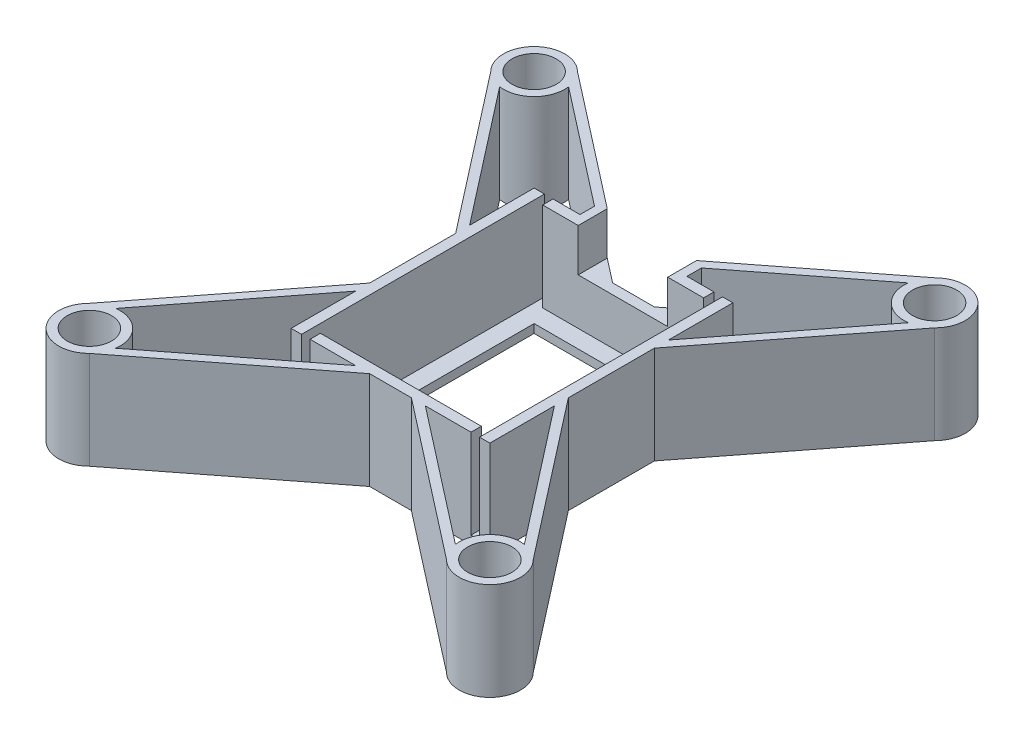
from build123d import *

# Parameters (mm, degrees)
SKETCH1_R           = 3.1
BOSS_EXTRUDE4_DEPTH = 13.7
SKETCH6_W           = 24.96
SKETCH6_H           = 31.16
CUT_EXTRUDE1_DEPTH  = 12.5
SKETCH7_W           = 19.96
SKETCH7_H           = 26.16
CUT_EXTRUDE2_DEPTH  = 12.5
SKETCH9_W           = 1.2
SKETCH9_H           = 12.5
CUT_EXTRUDE3_DEPTH  = 1.45
SKETCH10_W          = 1.2
SKETCH10_H          = 12.5
CUT_EXTRUDE4_DEPTH  = 1.45
CUT_EXTRUDE5_DEPTH  = 1.5
SKETCH12_W          = 7.5
SKETCH12_H          = 6
CUT_EXTRUDE6_DEPTH  = 20.892135624
BOSS_EXTRUDE5_DEPTH = 6
BOSS_EXTRUDE6_DEPTH = 7.7


with BuildPart() as part:
    # Sketch1 → Boss-Extrude4 (new body)
    with BuildSketch(Plane(origin=(0, 0, 0), x_dir=(1, 0, 0), z_dir=(0, 1, 0))):
        with BuildLine():
            Line((-1.559985024, 16.088570711), (-23.661955043, 33.271658997))
            ThreePointArc((-23.661955043, 33.271658997), (-29.74307331, 33.27087194), (-29.742286254, 27.189753673))
            Line((-29.742286254, 27.189753673), (-12.559985024, 5.088570711))
            Line((-12.559985024, 5.088570711), (-12.559985024, -6.971429289))
            Line((-12.559985024, -6.971429289), (-29.742286254, -29.072612251))
            ThreePointArc((-29.742286254, -29.072612251), (-29.74307331, -35.153730518), (-23.661955043, -35.154517574))
            Line((-23.661955043, -35.154517574), (-1.559985024, -17.971429289))
            Line((-1.559985024, -17.971429289), (4.300014976, -17.971429289))
            Line((4.300014976, -17.971429289), (26.401984994, -35.154517574))
            ThreePointArc((26.401984994, -35.154517574), (32.483103261, -35.153730518), (32.482316205, -29.072612251))
            Line((32.482316205, -29.072612251), (15.300014976, -6.971429289))
            Line((15.300014976, -6.971429289), (15.300014976, 5.088570711))
            Line((15.300014976, 5.088570711), (32.482316205, 27.189753673))
            ThreePointArc((32.482316205, 27.189753673), (32.483103261, 33.27087194), (26.401984994, 33.271658997))
            Line((26.401984994, 33.271658997), (4.300014976, 16.088570711))
            Line((4.300014976, 16.088570711), (-1.559985024, 16.088570711))
        make_face()
        with BuildLine():
            Line((15.300014976, -17.971429289), (15.300014976, -8.926547914))
            Line((15.300014976, -8.926547914), (30.013101167, -27.851638652))
            ThreePointArc((30.013101167, -27.851638652), (26.40152787, -29.073069325), (25.180248217, -32.684693693))
            Line((25.180248217, -32.684693693), (6.255121178, -17.971429289))
            Line((6.255121178, -17.971429289), (15.300014976, -17.971429289))
        make_face(mode=Mode.SUBTRACT)
        with Locations((-26.702120648, -32.113564912)):
            Circle(SKETCH1_R, mode=Mode.SUBTRACT)
        with BuildLine():
            Line((-12.559985024, -8.926547914), (-12.559985024, -17.971429289))
            Line((-12.559985024, -17.971429289), (-3.515091227, -17.971429289))
            Line((-3.515091227, -17.971429289), (-22.440218266, -32.684693693))
            ThreePointArc((-22.440218266, -32.684693693), (-23.661497919, -29.073069325), (-27.273071216, -27.851638652))
            Line((-27.273071216, -27.851638652), (-12.559985024, -8.926547914))
        make_face(mode=Mode.SUBTRACT)
        with BuildLine():
            Line((-3.515091227, 16.088570711), (-12.559985024, 16.088570711))
            Line((-12.559985024, 16.088570711), (-12.559985024, 7.043689336))
            Line((-12.559985024, 7.043689336), (-27.273071216, 25.968780075))
            ThreePointArc((-27.273071216, 25.968780075), (-23.661497919, 27.190210747), (-22.440218266, 30.801835115))
            Line((-22.440218266, 30.801835115), (-3.515091227, 16.088570711))
        make_face(mode=Mode.SUBTRACT)
        with Locations((-26.702120648, 30.230706335)):
            Circle(SKETCH1_R, mode=Mode.SUBTRACT)
        with BuildLine():
            Line((15.300014976, 7.043689336), (15.300014976, 16.088570711))
            Line((15.300014976, 16.088570711), (6.255121178, 16.088570711))
            Line((6.255121178, 16.088570711), (25.180248217, 30.801835115))
            ThreePointArc((25.180248217, 30.801835115), (26.40152787, 27.190210747), (30.013101167, 25.968780075))
            Line((30.013101167, 25.968780075), (15.300014976, 7.043689336))
        make_face(mode=Mode.SUBTRACT)
        with Locations((29.442150599, 30.230706335)):
            Circle(SKETCH1_R, mode=Mode.SUBTRACT)
        with Locations((29.442150599, -32.113564912)):
            Circle(SKETCH1_R, mode=Mode.SUBTRACT)
    extrude(amount=BOSS_EXTRUDE4_DEPTH)

    # Sketch6 → Cut-Extrude1 (cut)
    with BuildSketch(Plane(origin=(0, 13.7, 0), x_dir=(1, 0, 0), z_dir=(0, 1, 0))):
        with Locations((1.370014976, -0.941429289)):
            Rectangle(SKETCH6_W, SKETCH6_H)
    extrude(amount=-CUT_EXTRUDE1_DEPTH, mode=Mode.SUBTRACT)

    # Sketch7 → Cut-Extrude2 (cut)
    with BuildSketch(Plane(origin=(0, 1.2, 0), x_dir=(1, 0, 0), z_dir=(0, 1, 0))):
        with Locations((1.370014976, -0.941429289)):
            Rectangle(SKETCH7_W, SKETCH7_H)
    extrude(amount=-CUT_EXTRUDE2_DEPTH, mode=Mode.SUBTRACT)

    # Sketch9 → Cut-Extrude3 (cut)
    with BuildSketch(Plane.XY.offset(-14.638570711)):
        with Locations((-10.509985024, 7.45)):
            Rectangle(SKETCH9_W, SKETCH9_H)
        with Locations((13.250014976, 7.45)):
            Rectangle(SKETCH9_W, SKETCH9_H)
    extrude(amount=-CUT_EXTRUDE3_DEPTH, mode=Mode.SUBTRACT)

    # Sketch10 → Cut-Extrude4 (cut)
    with BuildSketch(Plane(origin=(0, 0, 16.521429289), x_dir=(-1, 0, 0), z_dir=(0, 0, -1))):
        with Locations((-13.250014976, 7.45)):
            Rectangle(SKETCH10_W, SKETCH10_H)
        with Locations((10.509985024, 7.45)):
            Rectangle(SKETCH10_W, SKETCH10_H)
    extrude(amount=-CUT_EXTRUDE4_DEPTH, mode=Mode.SUBTRACT)

    # Sketch11 → Cut-Extrude5 (cut)
    with BuildSketch(Plane.XZ):
        Polygon((-26.881022326, -29.561079875), (-26.032494188, -30.409608013), (-22.146132163, -26.523245987), (-22.9946603, -25.67471785), align=None)
        Polygon((24.886162114, -26.523245987), (25.734690251, -25.67471785), (29.621052277, -29.561079875), (28.772524139, -30.409608013), align=None)
        Polygon((29.621052277, 31.443938453), (28.772524139, 32.29246659), (24.886162114, 28.406104565), (25.734690251, 27.557576427), align=None)
        Polygon((-22.146132163, 28.406104565), (-22.9946603, 27.557576427), (-26.881022326, 31.443938453), (-26.032494188, 32.29246659), align=None)
    extrude(amount=-CUT_EXTRUDE5_DEPTH, mode=Mode.SUBTRACT)

    # Sketch12 → Cut-Extrude6 (cut, through all)
    with BuildSketch(Plane.XY.offset(-14.638570711)):
        with Locations((-2.379985024, 10.7)):
            Rectangle(SKETCH12_W, SKETCH12_H)
        with Locations((5.120014976, 10.7)):
            Rectangle(SKETCH12_W, SKETCH12_H)
    extrude(amount=-CUT_EXTRUDE6_DEPTH, mode=Mode.SUBTRACT)

    # Sketch14 → Boss-Extrude5 (add)
    with BuildSketch(Plane(origin=(0, 7.7, 0), x_dir=(1, 0, 0), z_dir=(0, 1, 0))):
        Polygon((-6.129985024, 19.641498953), (-6.129985024, 14.638570711), (-4.929985024, 14.638570711), (-4.929985024, 18.708563747), align=None)
        Polygon((8.870014976, 19.641498953), (8.870014976, 14.638570711), (7.62204126, 14.638570711), (7.62204126, 18.671266773), align=None)
    extrude(amount=BOSS_EXTRUDE5_DEPTH)

    # Sketch15 → Boss-Extrude6 (add)
    with BuildSketch(Plane.XZ.offset(-7.7)):
        Polygon((-6.129985024, -16.088570711), (-6.129985024, -18.121509447), (-3.515091227, -16.088570711), align=None)
        Polygon((8.870014976, -16.088570711), (8.870014976, -18.121509447), (6.255121178, -16.088570711), align=None)
    extrude(amount=BOSS_EXTRUDE6_DEPTH)


solid = part.part
